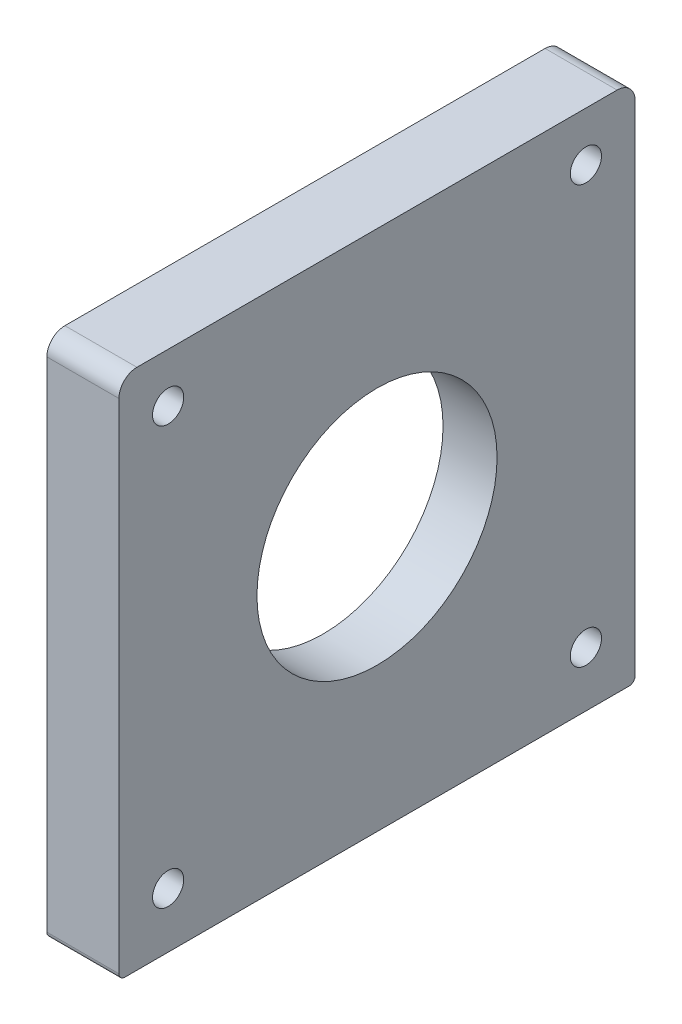
from build123d import *

# Parameters (mm, degrees)
SKETCH1_W           = 40
SKETCH1_H           = 86
BOSS_EXTRUDE1_DEPTH = 12
SKETCH2_W           = 12
SKETCH2_H           = 86
BOSS_EXTRUDE2_DEPTH = 87
SKETCH3_R           = 3
CUT_EXTRUDE1_DEPTH  = 13
SKETCH4_R           = 38
CUT_EXTRUDE2_DEPTH  = 3
SKETCH5_R           = 2.6
CUT_EXTRUDE3_DEPTH  = 13
FILLET1_R           = 3
SKETCH6_R           = 20
CUT_EXTRUDE4_DEPTH  = 13
SKETCH7_W           = 40
SKETCH7_H           = 12
CUT_EXTRUDE5_DEPTH  = 87
FILLET2_R           = 1
SKETCH8_R           = 2.1
CUT_EXTRUDE6_DEPTH  = 12


with BuildPart() as part:
    # Sketch1 → Boss-Extrude1 (new body)
    with BuildSketch(Plane(origin=(0, 0, 0), x_dir=(1, 0, 0), z_dir=(0, 1, 0))):
        with Locations((20, -43)):
            Rectangle(SKETCH1_W, SKETCH1_H)
    extrude(amount=BOSS_EXTRUDE1_DEPTH)

    # Sketch2 → Boss-Extrude2 (add)
    with BuildSketch(Plane(origin=(0, 12, 0), x_dir=(1, 0, 0), z_dir=(0, 1, 0))):
        with Locations((34, -43)):
            Rectangle(SKETCH2_W, SKETCH2_H)
    extrude(amount=BOSS_EXTRUDE2_DEPTH)

    # Sketch3 → Cut-Extrude1 (cut, through all)
    with BuildSketch(Plane(origin=(0, 12, 0), x_dir=(1, 0, 0), z_dir=(0, 1, 0))):
        with Locations((14, -8.4)):
            Circle(SKETCH3_R)
        with Locations((14, -77.6)):
            Circle(SKETCH3_R)
    extrude(amount=-CUT_EXTRUDE1_DEPTH, mode=Mode.SUBTRACT)

    # Sketch4 → Cut-Extrude2 (cut)
    with BuildSketch(Plane.ZY.offset(-28)):
        with Locations((43, 56)):
            Circle(SKETCH4_R)
    extrude(amount=-CUT_EXTRUDE2_DEPTH, mode=Mode.SUBTRACT)

    # Sketch5 → Cut-Extrude3 (cut, through all)
    with BuildSketch(Plane.ZY.offset(-28)):
        with Locations((77.8, 90.8)):
            Circle(SKETCH5_R)
        with Locations((77.8, 21.2)):
            Circle(SKETCH5_R)
        with Locations((8.2, 90.8)):
            Circle(SKETCH5_R)
        with Locations((8.2, 21.2)):
            Circle(SKETCH5_R)
    extrude(amount=-CUT_EXTRUDE3_DEPTH, mode=Mode.SUBTRACT)

    # Fillet1
    fillet1_edges = [part.edges().sort_by_distance(p)[0] for p in [
        (34, 99, 0),
        (34, 99, 86),
    ]]
    fillet(fillet1_edges, radius=FILLET1_R)

    # Sketch6 → Cut-Extrude4 (cut, through all)
    with BuildSketch(Plane.ZY.offset(-28)):
        with Locations((43, 56)):
            Circle(SKETCH6_R)
    extrude(amount=-CUT_EXTRUDE4_DEPTH, mode=Mode.SUBTRACT)

    # Sketch7 → Cut-Extrude5 (cut, through all)
    with BuildSketch(Plane.XY.offset(86)):
        with Locations((20, 6)):
            Rectangle(SKETCH7_W, SKETCH7_H)
    extrude(amount=-CUT_EXTRUDE5_DEPTH, mode=Mode.SUBTRACT)

    # Fillet2
    fillet2_edges = [part.edges().sort_by_distance(p)[0] for p in [
        (34, 12, 0),
        (34, 12, 86),
    ]]
    fillet(fillet2_edges, radius=FILLET2_R)

    # Sketch8 → Cut-Extrude6 (cut)
    with BuildSketch(Plane.XZ.offset(-12)):
        with Locations((34, 70)):
            Circle(SKETCH8_R)
        with Locations((34, 16)):
            Circle(SKETCH8_R)
    extrude(amount=-CUT_EXTRUDE6_DEPTH, mode=Mode.SUBTRACT)


solid = part.part
